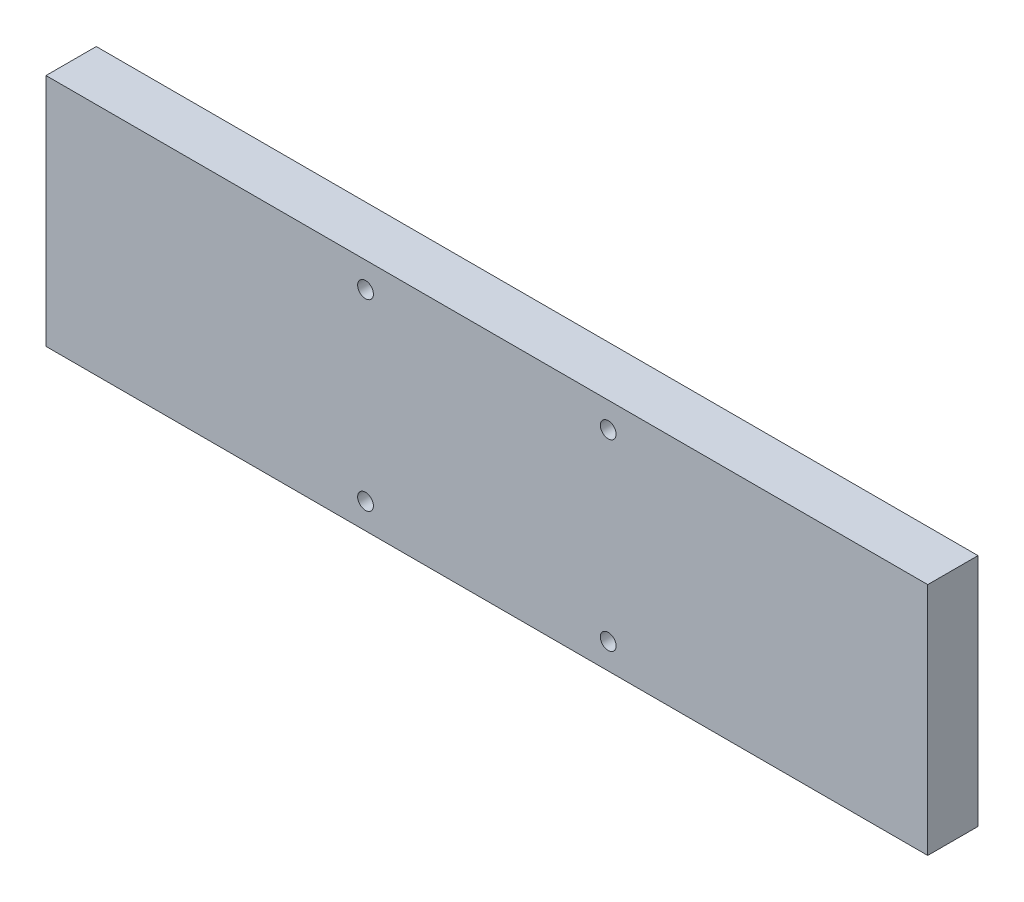
from build123d import *

# Parameters (mm, degrees)
SKETCH1_W           = 327
SKETCH1_H           = 87
BOSS_EXTRUDE1_DEPTH = 18.64
SKETCH5_R           = 2.925
CUT_EXTRUDE4_DEPTH  = 19.64


with BuildPart() as part:
    # Sketch1 → Boss-Extrude1 (new body)
    with BuildSketch(Plane.XY):
        with Locations((5192.528255097, 1838.223775404)):
            Rectangle(SKETCH1_W, SKETCH1_H)
    extrude(amount=BOSS_EXTRUDE1_DEPTH)

    # Sketch5 → Cut-Extrude4 (cut, through all)
    with BuildSketch(Plane.XY.offset(18.64)):
        with Locations((5147.528255097, 1872.223775404)):
            Circle(SKETCH5_R)
        with Locations((5147.528255097, 1804.223775404)):
            Circle(SKETCH5_R)
        with Locations((5237.528255097, 1804.223775404)):
            Circle(SKETCH5_R)
        with Locations((5237.528255097, 1872.223775404)):
            Circle(SKETCH5_R)
    extrude(amount=-CUT_EXTRUDE4_DEPTH, mode=Mode.SUBTRACT)


solid = part.part
